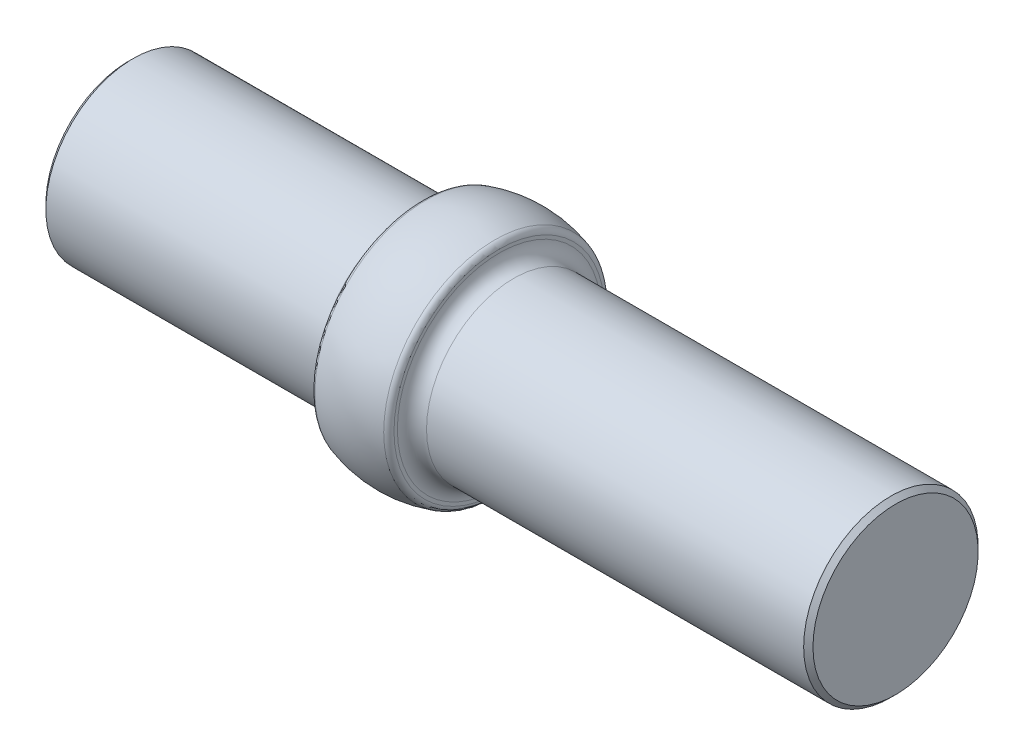
from build123d import *

# Parameters (mm, degrees)
FILLET1_R          = 2.3876
CHAMFER1_SIZE      = 0.762
FILLET2_R          = 1.016
SKETCH2_W          = 1.017628205
SKETCH2_H          = 0.271367522
SKETCH2_W_2        = 1.89957265
SKETCH2_H_2        = 0.169604701
CUT_EXTRUDE1_DEPTH = 0.0254


with BuildPart() as part:
    # Sketch1 → Revolve1 (revolve)
    with BuildSketch(Plane.XY, mode=Mode.PRIVATE) as revolve1_sk:
        with BuildLine():
            Line((71.247, 14.2875), (71.247, 0))
            Line((71.247, 0), (-54.356, 0))
            Line((-54.356, 0), (-54.356, 14.2875))
            Line((-54.356, 14.2875), (-6.35, 14.2875))
            Line((-6.35, 14.2875), (-6.35, 17.960512242))
            ThreePointArc((-6.35, 17.960512242), (0, 19.05), (6.35, 17.960512242))
            Line((6.35, 17.960512242), (6.35, 14.2875))
            Line((6.35, 14.2875), (71.247, 14.2875))
        make_face()
    revolve(revolve1_sk.sketch.rotate(Axis((0, 0, 0), (1, 0, 0)), 90), axis=Axis((0, 0, 0), (1, 0, 0)))  # turned: the seam where the file's is

    # Fillet1
    fillet1_edges = [part.edges().sort_by_distance(p)[0] for p in [
        (6.35, 0, -14.2875),
        (-6.35, 0, -14.2875),
    ]]
    fillet(fillet1_edges, radius=FILLET1_R)

    # Chamfer1
    chamfer1_edges = [part.edges().sort_by_distance(p)[0] for p in [
        (-54.356, 0, -14.2875),
        (71.247, 0, -14.2875),
    ]]
    chamfer(chamfer1_edges, length=CHAMFER1_SIZE)

    # Fillet2
    fillet2_edges = [part.edges().sort_by_distance(p)[0] for p in [
        (6.35, 0, -17.960512242),
        (-6.35, 0, -17.960512242),
    ]]
    fillet(fillet2_edges, radius=FILLET2_R)

    # Sketch2 → Cut-Extrude1 (cut)
    with BuildSketch(Plane.ZY.offset(54.356)):
        with BuildLine():
            Line((-9.921875, 1.016), (-9.921875, 3.661833333))
            Line((-9.921875, 3.661833333), (-9.387620192, 3.661833333))
            add(Edge.make_bspline(
                [(-9.387620192, 3.661833333), (-9.341152564, 3.661498771), (-9.251377349, 3.6608524), (-9.121646511, 3.656754086), (-9.001613547, 3.649504151), (-8.891673231, 3.638943854), (-8.791523744, 3.625976978), (-8.70144551, 3.609723696), (-8.620972759, 3.590531448), (-8.57148098, 3.574168518), (-8.548076923, 3.566430689)],
                knots=[0, 0, 0, 0, 1.314313732, 2.53924729, 3.670748893, 4.714932338, 5.66265055, 6.526160246, 7.303039223, 8, 8, 8, 8], degree=3))
            add(Edge.make_bspline(
                [(-8.548076923, 3.566430689), (-8.517464828, 3.55476581), (-8.45693482, 3.531700574), (-8.370750864, 3.488190751), (-8.289618001, 3.438892751), (-8.213101147, 3.383741593), (-8.142948141, 3.321175687), (-8.076418362, 3.253852771), (-8.016233422, 3.17932468), (-7.961118222, 3.099137041), (-7.911425194, 3.014234477), (-7.868230712, 2.92477877), (-7.832357752, 2.831224214), (-7.802578349, 2.733830977), (-7.779108705, 2.632384906), (-7.763096174, 2.526767876), (-7.752534771, 2.417397299), (-7.751473375, 2.343182079), (-7.750934829, 2.305525741)],
                knots=[0, 0, 0, 0, 0.984719456, 1.947108742, 2.898477687, 3.838006223, 4.779231079, 5.722358779, 6.681677486, 7.655904652, 8.64651281, 9.637519902, 10.640069247, 11.656948941, 12.698408672, 13.768548281, 14.867775369, 16, 16, 16, 16], degree=3))
            add(Edge.make_bspline(
                [(-7.750934829, 2.305525741), (-7.751410299, 2.272822305), (-7.752347261, 2.208376768), (-7.760760494, 2.113398234), (-7.772989021, 2.021237379), (-7.791921242, 1.93233307), (-7.814904095, 1.845906382), (-7.844359138, 1.762878435), (-7.878101447, 1.682487579), (-7.917448677, 1.605820797), (-7.960644843, 1.533186343), (-8.007001161, 1.464715557), (-8.056468186, 1.401385478), (-8.109517623, 1.343004325), (-8.165463933, 1.289660108), (-8.224673397, 1.240907216), (-8.287298798, 1.197699582), (-8.353059642, 1.158339328), (-8.423874335, 1.124003702), (-8.501084186, 1.094952444), (-8.58501847, 1.07087792), (-8.675471163, 1.050791588), (-8.772598554, 1.03485815), (-8.876495868, 1.02417927), (-8.987003474, 1.016957708), (-9.062885418, 1.016325435), (-9.101942274, 1.016)],
                knots=[0, 0, 0, 0, 1.105936401, 2.179363191, 3.223086493, 4.248585256, 5.251745608, 6.245858792, 7.225916811, 8.198733463, 9.158002045, 10.082870192, 10.993790845, 11.873723703, 12.748670949, 13.606408763, 14.465103618, 15.319838547, 16.196477973, 17.123216899, 18.106603292, 19.147568657, 20.255746949, 21.433717677, 22.679120308, 24, 24, 24, 24], degree=3))
            Line((-9.101942274, 1.016), (-9.921875, 1.016))
        make_face()
        with BuildLine():
            Line((-9.684428419, 1.287367521), (-9.380730001, 1.287367521))
            add(Edge.make_bspline(
                [(-9.380730001, 1.287367521), (-9.337090102, 1.28755507), (-9.253154594, 1.287915796), (-9.132460751, 1.291081122), (-9.022182873, 1.296253301), (-8.922305304, 1.303491604), (-8.832884434, 1.313068474), (-8.753733385, 1.323746228), (-8.685111613, 1.337049062), (-8.643587574, 1.349107228), (-8.624399038, 1.354679387)],
                knots=[0, 0, 0, 0, 1.375205317, 2.645023457, 3.804390687, 4.853969522, 5.800190428, 6.637939096, 7.370582563, 8, 8, 8, 8], degree=3))
            add(Edge.make_bspline(
                [(-8.624399038, 1.354679387), (-8.600247598, 1.363185029), (-8.552521574, 1.379993157), (-8.483819801, 1.410652817), (-8.419747542, 1.446970334), (-8.359188177, 1.48733991), (-8.303000765, 1.5331854), (-8.250519439, 1.583509897), (-8.201849863, 1.638569519), (-8.15749488, 1.698295927), (-8.117801103, 1.76231738), (-8.083427019, 1.830004474), (-8.053301159, 1.900615575), (-8.029656032, 1.975234998), (-8.011123418, 2.053195655), (-7.997996541, 2.134503031), (-7.989821124, 2.21914194), (-7.988867529, 2.27670932), (-7.98838141, 2.306055756)],
                knots=[0, 0, 0, 0, 0.998632004, 1.973411704, 2.929992603, 3.868527914, 4.809262121, 5.754881198, 6.702106254, 7.672490631, 8.653608572, 9.636854334, 10.631411391, 11.644891563, 12.686317036, 13.754757253, 14.855430412, 16, 16, 16, 16], degree=3))
            add(Edge.make_bspline(
                [(-7.98838141, 2.306055756), (-7.988769431, 2.336999518), (-7.989531701, 2.397788812), (-7.999112877, 2.486984159), (-8.01311429, 2.572770127), (-8.033361482, 2.655152453), (-8.059162801, 2.734291862), (-8.091362322, 2.809750659), (-8.128151968, 2.882325768), (-8.171924134, 2.950342104), (-8.219863303, 3.014668442), (-8.273065628, 3.073598646), (-8.33068586, 3.127266957), (-8.392095537, 3.176509175), (-8.459025368, 3.219344216), (-8.529898694, 3.257660933), (-8.605755243, 3.290178899), (-8.658530317, 3.307474229), (-8.685350728, 3.316263755)],
                knots=[0, 0, 0, 0, 1.122418816, 2.205001699, 3.251619955, 4.274784885, 5.280384055, 6.268708349, 7.249350384, 8.229342522, 9.199999885, 10.157847722, 11.105861043, 12.055065948, 13.010012805, 13.98527497, 14.976112212, 16, 16, 16, 16], degree=3))
            add(Edge.make_bspline(
                [(-8.685350728, 3.316263755), (-8.707538797, 3.322399388), (-8.754716719, 3.335445427), (-8.831702505, 3.349676513), (-8.9183461, 3.362228723), (-9.015032183, 3.372855932), (-9.121650542, 3.380481466), (-9.238283175, 3.386205019), (-9.364980495, 3.39006539), (-9.452808959, 3.390328996), (-9.498393263, 3.390465812)],
                knots=[0, 0, 0, 0, 0.674548936, 1.434276114, 2.292660221, 3.240891867, 4.284742987, 5.42552168, 6.663806718, 8, 8, 8, 8], degree=3))
            Line((-9.498393263, 3.390465812), (-9.684428419, 3.390465812))
            Line((-9.684428419, 3.390465812), (-9.684428419, 1.287367521))
        make_face(mode=Mode.SUBTRACT)
        with BuildLine():
            add(Edge.make_bspline(
                [(-7.445646368, 2.337856637), (-7.445398401, 2.380263591), (-7.444916724, 2.46263971), (-7.439558215, 2.582673338), (-7.430656617, 2.695280224), (-7.418457532, 2.800465756), (-7.403612154, 2.898257089), (-7.383794494, 2.988392888), (-7.361257435, 3.071290329), (-7.335137431, 3.147219734), (-7.305664519, 3.217204069), (-7.273586239, 3.282537406), (-7.237629519, 3.343120891), (-7.199849353, 3.399921482), (-7.158716418, 3.452009394), (-7.115401261, 3.500120217), (-7.068213295, 3.543142034), (-7.018756616, 3.58233537), (-6.966583455, 3.616693006), (-6.913180964, 3.64695585), (-6.858181568, 3.672809321), (-6.801435109, 3.69313721), (-6.743451627, 3.709927553), (-6.684028428, 3.721409674), (-6.623067397, 3.728634242), (-6.581919824, 3.729324931), (-6.56105185, 3.729675214)],
                knots=[0, 0, 0, 0, 1.646270934, 3.197905019, 4.663502075, 6.030701355, 7.308322542, 8.50163776, 9.611534131, 10.641858119, 11.616356847, 12.558055219, 13.465016945, 14.349605745, 15.204443733, 16.039544428, 16.859896111, 17.680448484, 18.487036065, 19.28249412, 20.06191084, 20.843045899, 21.620316918, 22.403196591, 23.190181807, 24, 24, 24, 24], degree=3))
            add(Edge.make_bspline(
                [(-6.56105185, 3.729675214), (-6.540009553, 3.729306449), (-6.498163047, 3.728573091), (-6.43629562, 3.721524634), (-6.375857468, 3.709829202), (-6.317106256, 3.693257989), (-6.259559391, 3.672699353), (-6.203666988, 3.646931115), (-6.149081872, 3.616935781), (-6.096671477, 3.58169035), (-6.045860428, 3.542394225), (-5.997896789, 3.497972445), (-5.952776195, 3.44887355), (-5.909932363, 3.395622855), (-5.87058081, 3.337199012), (-5.833105656, 3.274618167), (-5.79956251, 3.206785906), (-5.76725713, 3.134834005), (-5.739372325, 3.056771596), (-5.714224627, 2.973038711), (-5.693905407, 2.88264632), (-5.676980183, 2.786068682), (-5.663868268, 2.682951121), (-5.654318592, 2.57351468), (-5.649274058, 2.457687361), (-5.648324051, 2.378495415), (-5.647836538, 2.337856637)],
                knots=[0, 0, 0, 0, 0.810914788, 1.612654377, 2.396697861, 3.181598691, 3.963628158, 4.749916497, 5.551656086, 6.361998678, 7.18212741, 8.025565596, 8.878627764, 9.750805457, 10.657531673, 11.591944965, 12.560506719, 13.57287815, 14.630710178, 15.753379473, 16.941251878, 18.199788006, 19.531962791, 20.947069417, 22.433333509, 24, 24, 24, 24], degree=3))
            add(Edge.make_bspline(
                [(-5.647836538, 2.337856637), (-5.648329105, 2.297395112), (-5.649288852, 2.218557479), (-5.654262041, 2.103251325), (-5.664058149, 1.994395661), (-5.676312128, 1.891729419), (-5.693283987, 1.795679909), (-5.714152178, 1.705914761), (-5.737322363, 1.622046326), (-5.765923666, 1.544761676), (-5.797228191, 1.472982696), (-5.831287773, 1.405954554), (-5.867777463, 1.343084797), (-5.90753205, 1.284876655), (-5.949905762, 1.230917789), (-5.995805519, 1.182160657), (-6.043937449, 1.137430447), (-6.094898025, 1.097628324), (-6.148125805, 1.062790406), (-6.202523441, 1.031634698), (-6.259056117, 1.006512363), (-6.316442695, 0.984941231), (-6.375504019, 0.968461127), (-6.436166469, 0.95706601), (-6.498121481, 0.949074196), (-6.540002426, 0.948464536), (-6.56105185, 0.94815812)],
                knots=[0, 0, 0, 0, 1.561518951, 3.042555995, 4.452378317, 5.7783523, 7.031515105, 8.214008947, 9.334062868, 10.386615937, 11.391082383, 12.354592575, 13.286541444, 14.194233754, 15.072674879, 15.931287219, 16.775624067, 17.606195743, 18.42308326, 19.229000347, 20.022332153, 20.807536673, 21.593273796, 22.3848459, 23.188221202, 24, 24, 24, 24], degree=3))
            add(Edge.make_bspline(
                [(-6.56105185, 0.94815812), (-6.581919245, 0.948510662), (-6.623065677, 0.949205807), (-6.68403507, 0.956397735), (-6.743212869, 0.967960407), (-6.800891094, 0.98415034), (-6.857365662, 1.003967508), (-6.911867021, 1.029786066), (-6.965001163, 1.05952075), (-7.016626328, 1.093383955), (-7.065772426, 1.132180704), (-7.112716014, 1.175091803), (-7.156277784, 1.223188072), (-7.196822607, 1.275710073), (-7.23535659, 1.332174608), (-7.270802723, 1.393352604), (-7.303589024, 1.459001482), (-7.333557615, 1.529545379), (-7.360128331, 1.606013688), (-7.38359892, 1.689281221), (-7.402130455, 1.780082922), (-7.417992571, 1.877689504), (-7.430786598, 1.982520391), (-7.439521118, 2.094632498), (-7.444919612, 2.213955959), (-7.445399695, 2.295802753), (-7.445646368, 2.337856637)],
                knots=[0, 0, 0, 0, 0.810891512, 1.598919785, 2.382837074, 3.152667961, 3.926044502, 4.706494248, 5.493654104, 6.291793342, 7.103789334, 7.925228297, 8.761435821, 9.622817696, 10.50288917, 11.416980706, 12.369136599, 13.353924996, 14.394355917, 15.514179734, 16.714354668, 17.994756427, 19.357759367, 20.818452758, 22.365282078, 24, 24, 24, 24], degree=3))
        make_face()
        with BuildLine():
            add(Edge.make_bspline(
                [(-7.208199786, 2.338916667), (-7.20810949, 2.303576876), (-7.207934243, 2.234989283), (-7.203356043, 2.135322056), (-7.197119261, 2.042362343), (-7.189074947, 1.95599211), (-7.17712867, 1.876503708), (-7.163743182, 1.803350436), (-7.147453852, 1.736919429), (-7.128180833, 1.676754834), (-7.106228658, 1.621835598), (-7.082260535, 1.570732298), (-7.056512251, 1.522841251), (-7.027695988, 1.47859263), (-6.996312577, 1.437842137), (-6.963070887, 1.399868508), (-6.926730303, 1.366004123), (-6.87645664, 1.325389179), (-6.810086686, 1.283419358), (-6.72646289, 1.246872016), (-6.640534954, 1.223904326), (-6.582212282, 1.220983511), (-6.553101629, 1.219525641)],
                knots=[0, 0, 0, 0, 1.459021318, 2.831673884, 4.118529203, 5.306027144, 6.411944654, 7.436330062, 8.375795394, 9.233974572, 10.042671642, 10.816086306, 11.563610507, 12.285937304, 12.993564865, 13.685989202, 14.367179055, 15.041617293, 16.353048772, 17.594441528, 18.799311195, 20, 20, 20, 20], degree=3))
            add(Edge.make_bspline(
                [(-6.553101629, 1.219525641), (-6.523802675, 1.220733487), (-6.465265258, 1.223146686), (-6.379741496, 1.246429065), (-6.296715042, 1.281557824), (-6.231648754, 1.323095521), (-6.182147069, 1.362653247), (-6.146680059, 1.396379796), (-6.114127201, 1.434144053), (-6.083252537, 1.474889354), (-6.05493526, 1.519394149), (-6.02918515, 1.567444429), (-6.005687619, 1.619173629), (-5.992300424, 1.655285277), (-5.985455896, 1.673748231)],
                knots=[0, 0, 0, 0, 1.353760809, 2.704726607, 4.075137775, 5.516104923, 6.260822281, 7.007110065, 7.778089737, 8.566572457, 9.372053459, 10.217411131, 11.088608312, 12, 12, 12, 12], degree=3))
            add(Edge.make_bspline(
                [(-5.985455896, 1.673748231), (-5.977479262, 1.697356426), (-5.961283274, 1.745291189), (-5.940410088, 1.819649426), (-5.923971601, 1.897665801), (-5.909182629, 1.978874074), (-5.899088354, 2.063873133), (-5.890963519, 2.152399983), (-5.886177821, 2.24452137), (-5.885584587, 2.307110441), (-5.88528312, 2.338916667)],
                knots=[0, 0, 0, 0, 0.884706709, 1.796334032, 2.740027952, 3.714592787, 4.726048262, 5.777819803, 6.87074269, 8, 8, 8, 8], degree=3))
            add(Edge.make_bspline(
                [(-5.88528312, 2.338916667), (-5.885699037, 2.370717748), (-5.886512659, 2.432927462), (-5.889622638, 2.524033468), (-5.897653554, 2.610565644), (-5.906573126, 2.692896775), (-5.919724597, 2.770571111), (-5.933904606, 2.844238902), (-5.952955522, 2.912987498), (-5.97330559, 2.977893253), (-5.996596782, 3.038218748), (-6.022235462, 3.094245241), (-6.049617387, 3.146243217), (-6.079358247, 3.194070012), (-6.111104984, 3.237939851), (-6.145695512, 3.276973146), (-6.181757746, 3.312379664), (-6.232268357, 3.35279482), (-6.298394754, 3.394003066), (-6.380676881, 3.431925992), (-6.466304094, 3.453703689), (-6.524189979, 3.456774131), (-6.553101629, 3.458307692)],
                knots=[0, 0, 0, 0, 1.31362396, 2.569729283, 3.763502607, 4.902122613, 5.988968491, 7.01645872, 7.998833611, 8.933434873, 9.825090667, 10.667526885, 11.477055099, 12.250526234, 12.991942729, 13.710640831, 14.402115721, 15.076753259, 16.378508321, 17.609869233, 18.806226677, 20, 20, 20, 20], degree=3))
            add(Edge.make_bspline(
                [(-6.553101629, 3.458307692), (-6.582364994, 3.456772015), (-6.640945033, 3.453697864), (-6.727462237, 3.432007131), (-6.810393503, 3.39419971), (-6.876345037, 3.352658333), (-6.926890876, 3.313093062), (-6.96248315, 3.278783064), (-6.995855554, 3.24125286), (-7.026598399, 3.200127603), (-7.055392083, 3.155930569), (-7.081836063, 3.108314062), (-7.105661663, 3.057036781), (-7.127648187, 3.002142214), (-7.146979997, 2.941982809), (-7.162926029, 2.87563363), (-7.177657313, 2.802713033), (-7.18808588, 2.722794119), (-7.197356695, 2.636402253), (-7.203314619, 2.543210471), (-7.207949557, 2.443376088), (-7.208114706, 2.374433867), (-7.208199786, 2.338916667)],
                knots=[0, 0, 0, 0, 1.207732386, 2.417664972, 3.655092373, 4.956220595, 5.625982001, 6.301752483, 6.994047911, 7.697131622, 8.419323945, 9.170223765, 9.943494443, 10.752040957, 11.610060368, 12.549350801, 13.567764191, 14.679664412, 15.874934091, 17.154273443, 18.533957287, 20, 20, 20, 20], degree=3))
        make_face(mode=Mode.SUBTRACT)
        Polygon((-3.966099927, 3.729675214), (-3.91786859, 3.729675214), (-3.91786859, 1.897944444), (-3.612580128, 1.897944444), (-3.612580128, 1.626576923), (-3.91786859, 1.626576923), (-3.91786859, 1.016), (-4.155315171, 1.016), (-4.155315171, 1.626576923), (-5.410389957, 1.626576923), align=None)
        Polygon((-4.155315171, 1.897944444), (-4.155315171, 3.047016293), (-4.94397703, 1.897944444), align=None, mode=Mode.SUBTRACT)
        Polygon((-3.205528846, 3.661833333), (-1.577323718, 3.661833333), (-2.968082265, 0.94815812), (-3.17319795, 1.061051249), (-1.979074853, 3.390465812), (-3.205528846, 3.390465812), align=None)
        with BuildLine():
            Line((-0.763221154, 0.94815812), (-0.952966413, 1.080131778))
            Line((-0.952966413, 1.080131778), (-0.217306023, 2.155531584))
            add(Edge.make_bspline(
                [(-0.217306023, 2.155531584), (-0.264243662, 2.14979159), (-0.356666491, 2.138489221), (-0.449752277, 2.136412881), (-0.495563735, 2.135391026)],
                knots=[0, 0, 0, 0, 1.015715272, 2, 2, 2, 2], degree=3))
            add(Edge.make_bspline(
                [(-0.495563735, 2.135391026), (-0.523338974, 2.136102435), (-0.577859338, 2.137498868), (-0.658014218, 2.148567378), (-0.73503485, 2.165614201), (-0.808717042, 2.191051057), (-0.879337739, 2.222663632), (-0.946742773, 2.261865065), (-1.010841404, 2.307982916), (-1.07094522, 2.360773333), (-1.125609451, 2.418738289), (-1.174310396, 2.48008809), (-1.214784943, 2.545535402), (-1.248407123, 2.613745151), (-1.27390574, 2.68569772), (-1.292473849, 2.76057435), (-1.303905629, 2.838899817), (-1.305265659, 2.892213458), (-1.305956197, 2.919282752)],
                knots=[0, 0, 0, 0, 1.060718605, 2.082097864, 3.085795603, 4.069760067, 5.054557537, 6.03741023, 7.043284206, 8.066802108, 9.088538119, 10.083643548, 11.053783639, 12.022749082, 12.983451788, 13.964007469, 14.966251758, 16, 16, 16, 16], degree=3))
            add(Edge.make_bspline(
                [(-1.305956197, 2.919282752), (-1.304645046, 2.956300722), (-1.302071525, 3.028959487), (-1.28135955, 3.135120729), (-1.24729608, 3.235501033), (-1.199800819, 3.329836477), (-1.139978738, 3.416770048), (-1.068081172, 3.495093222), (-0.984545438, 3.563692011), (-0.891274506, 3.622659379), (-0.790465973, 3.670084049), (-0.684883118, 3.705038759), (-0.575334944, 3.725599717), (-0.50112486, 3.728310457), (-0.463762854, 3.729675214)],
                knots=[0, 0, 0, 0, 1.022988612, 2.007919123, 2.978103895, 3.94594894, 4.918897164, 5.887013414, 6.875921846, 7.89917871, 8.930658928, 9.948724884, 10.967259574, 12, 12, 12, 12], degree=3))
            add(Edge.make_bspline(
                [(-0.463762854, 3.729675214), (-0.427107918, 3.728291698), (-0.354681219, 3.725558), (-0.248175839, 3.705537381), (-0.146166856, 3.671794182), (-0.049219753, 3.625163589), (0.040541589, 3.566712664), (0.121259018, 3.497063352), (0.191090526, 3.416172269), (0.249921674, 3.325995851), (0.29714605, 3.229107716), (0.33121855, 3.127973441), (0.352192931, 3.02332036), (0.354835988, 2.952416204), (0.356169872, 2.916632679)],
                knots=[0, 0, 0, 0, 1.026385292, 2.028040595, 3.023318987, 4.028184125, 5.03290303, 6.015178782, 7.004435299, 8.016004309, 9.023023918, 10.015172535, 10.998308025, 12, 12, 12, 12], degree=3))
            add(Edge.make_bspline(
                [(0.356169872, 2.916632679), (0.355279051, 2.888856141), (0.353472243, 2.832518381), (0.340820392, 2.746921634), (0.319336085, 2.659646002), (0.294955337, 2.585773129), (0.271420901, 2.524761384), (0.24927064, 2.476568225), (0.224693, 2.425842866), (0.196028219, 2.373117199), (0.165213864, 2.317719093), (0.130395244, 2.260204182), (0.092366628, 2.200495289), (0.065281066, 2.160243026), (0.051411425, 2.139631143)],
                knots=[0, 0, 0, 0, 1.179839688, 2.393009684, 3.667231171, 4.993948276, 5.694988576, 6.444077775, 7.246288328, 8.089075292, 8.993003841, 9.939041771, 10.944649915, 12, 12, 12, 12], degree=3))
            Line((0.051411425, 2.139631143), (-0.763221154, 0.94815812))
        make_face()
        with BuildLine():
            add(Edge.make_bspline(
                [(-0.451572516, 2.406758547), (-0.430531327, 2.407333361), (-0.389571284, 2.408452328), (-0.329565826, 2.415262886), (-0.272926696, 2.427338459), (-0.219502597, 2.44466467), (-0.168757856, 2.465571795), (-0.121498489, 2.492190379), (-0.077684944, 2.523952954), (-0.037023832, 2.559641478), (-0.000916523, 2.599291622), (0.031243983, 2.64079122), (0.05857965, 2.684322443), (0.080172127, 2.730430445), (0.097925348, 2.777992859), (0.110185392, 2.827775615), (0.116977121, 2.879519347), (0.118134918, 2.914670118), (0.118723291, 2.93253312)],
                knots=[0, 0, 0, 0, 1.163407946, 2.26475976, 3.333800367, 4.359385343, 5.366239384, 6.363380779, 7.350133999, 8.353570782, 9.349036268, 10.310270964, 11.253520213, 12.184142, 13.120487599, 14.056272588, 15.012232024, 16, 16, 16, 16], degree=3))
            add(Edge.make_bspline(
                [(0.118723291, 2.93253312), (0.118217053, 2.950403581), (0.117219449, 2.985619517), (0.109215954, 3.037439856), (0.095136172, 3.087100833), (0.076244556, 3.134874324), (0.051358424, 3.18036782), (0.02149567, 3.224152485), (-0.013983028, 3.2659507), (-0.054806396, 3.304779426), (-0.098828945, 3.340572183), (-0.145743728, 3.372160467), (-0.195164051, 3.398634824), (-0.24678841, 3.420481069), (-0.300724364, 3.437529137), (-0.356939998, 3.449788693), (-0.415719382, 3.456570912), (-0.455619521, 3.457721392), (-0.475953192, 3.458307692)],
                knots=[0, 0, 0, 0, 0.972161553, 1.915763587, 2.844109794, 3.775983486, 4.705125789, 5.659731448, 6.655561913, 7.682237399, 8.721216875, 9.739758359, 10.754845918, 11.767244016, 12.7857855, 13.828538656, 14.893392813, 16, 16, 16, 16], degree=3))
            add(Edge.make_bspline(
                [(-0.475953192, 3.458307692), (-0.496110022, 3.457720445), (-0.535657557, 3.456568269), (-0.593914392, 3.449801584), (-0.649749917, 3.437446689), (-0.703529595, 3.420488965), (-0.755152419, 3.398633194), (-0.804570412, 3.37215908), (-0.851496168, 3.340579455), (-0.895476511, 3.304751263), (-0.936371964, 3.266131436), (-0.971240667, 3.223969379), (-1.001171764, 3.180390596), (-1.026023701, 3.134868271), (-1.044924413, 3.087102448), (-1.05900176, 3.037439418), (-1.067005909, 2.985619631), (-1.068003423, 2.950403619), (-1.068509615, 2.93253312)],
                knots=[0, 0, 0, 0, 1.099389452, 2.15699305, 3.192601482, 4.213358962, 5.227959689, 6.245255729, 7.266013209, 8.307253147, 9.336162325, 10.327954924, 11.284637477, 12.215801273, 13.149702402, 14.080068371, 15.025723358, 16, 16, 16, 16], degree=3))
            add(Edge.make_bspline(
                [(-1.068509615, 2.93253312), (-1.068051564, 2.914656208), (-1.067148203, 2.879399665), (-1.058433743, 2.827596975), (-1.043860281, 2.777939828), (-1.024342052, 2.729945389), (-0.998638469, 2.684080353), (-0.967097226, 2.640562169), (-0.930126962, 2.598897513), (-0.888221886, 2.559733728), (-0.842359645, 2.523786548), (-0.79337639, 2.492391557), (-0.742115383, 2.465878459), (-0.688396174, 2.444604913), (-0.632616867, 2.427511572), (-0.574276142, 2.415285142), (-0.513566939, 2.408517654), (-0.472435584, 2.407350542), (-0.451572516, 2.406758547)],
                knots=[0, 0, 0, 0, 0.952633368, 1.87876736, 2.791047057, 3.707742249, 4.635551637, 5.587206343, 6.568248508, 7.601284464, 8.641511608, 9.671105535, 10.699146789, 11.713763218, 12.747829548, 13.806491675, 14.887386225, 16, 16, 16, 16], degree=3))
        make_face(mode=Mode.SUBTRACT)
        with BuildLine():
            Line((1.034588675, 3.05125641), (0.797142094, 3.05125641))
            add(Edge.make_bspline(
                [(0.797142094, 3.05125641), (0.803574909, 3.07789049), (0.816150536, 3.129957939), (0.84238025, 3.204349142), (0.870954687, 3.274746089), (0.905266688, 3.339830621), (0.942692949, 3.400910744), (0.985572625, 3.456601094), (1.031927416, 3.508318038), (1.083199848, 3.554214355), (1.136969729, 3.5957749), (1.193994709, 3.631210211), (1.253127492, 3.661693351), (1.314777777, 3.686806264), (1.379129109, 3.705724368), (1.445599717, 3.719450049), (1.514363792, 3.72836357), (1.56104203, 3.729233492), (1.584743924, 3.729675214)],
                knots=[0, 0, 0, 0, 1.162005537, 2.271625781, 3.343758855, 4.383309926, 5.390229558, 6.379919256, 7.361854164, 8.333198761, 9.295911338, 10.242430842, 11.177959212, 12.116337295, 13.062827104, 14.020064771, 14.994644689, 16, 16, 16, 16], degree=3))
            add(Edge.make_bspline(
                [(1.584743924, 3.729675214), (1.619277901, 3.728632581), (1.68759257, 3.726570059), (1.787955112, 3.707735932), (1.88473729, 3.677932409), (1.976879758, 3.636752865), (2.062467501, 3.585962456), (2.138619261, 3.525512923), (2.204302838, 3.456570594), (2.259407516, 3.380421572), (2.302553498, 3.299039133), (2.334368792, 3.215279491), (2.353737563, 3.129341334), (2.356247746, 3.071316486), (2.357505342, 3.042246161)],
                knots=[0, 0, 0, 0, 1.083050992, 2.142477498, 3.193116406, 4.255571735, 5.30263384, 6.308962982, 7.297363603, 8.282367274, 9.249857812, 10.179914175, 11.08814088, 12, 12, 12, 12], degree=3))
            add(Edge.make_bspline(
                [(2.357505342, 3.042246161), (2.356625722, 3.014270786), (2.354904444, 2.959527319), (2.340289083, 2.879606902), (2.315693218, 2.804282597), (2.281622623, 2.733237313), (2.237519189, 2.666921512), (2.184093996, 2.605185987), (2.12096996, 2.547756921), (2.073134096, 2.514858272), (2.048506778, 2.497921074)],
                knots=[0, 0, 0, 0, 1.024540389, 2.004866551, 2.965041327, 3.920577974, 4.882998113, 5.874504559, 6.905732034, 8, 8, 8, 8], degree=3))
            add(Edge.make_bspline(
                [(2.048506778, 2.497921074), (2.076652211, 2.484330432), (2.132416455, 2.45740344), (2.208427867, 2.404595814), (2.277429595, 2.343623456), (2.315910382, 2.296041808), (2.335244725, 2.272134816)],
                knots=[0, 0, 0, 0, 1.015518401, 2.012035669, 3.001164323, 4, 4, 4, 4], degree=3))
            add(Edge.make_bspline(
                [(2.335244725, 2.272134816), (2.347975978, 2.254704253), (2.37323, 2.220128567), (2.4044021, 2.16453853), (2.432681609, 2.108332345), (2.454717787, 2.050003508), (2.471782555, 1.990228075), (2.483980627, 1.928903407), (2.491558401, 1.865979426), (2.49264361, 1.823409872), (2.493189103, 1.802011786)],
                knots=[0, 0, 0, 0, 1.025084078, 2.033381695, 3.024893161, 4.013698104, 4.991890475, 5.976764909, 6.982997093, 8, 8, 8, 8], degree=3))
            add(Edge.make_bspline(
                [(2.493189103, 1.802011786), (2.491832536, 1.76496277), (2.489125786, 1.691039093), (2.46493223, 1.581823083), (2.427426983, 1.475063328), (2.374164894, 1.372953182), (2.309253146, 1.277415632), (2.232027074, 1.191935327), (2.143364134, 1.11845781), (2.044481293, 1.057066745), (1.937349892, 1.007991887), (1.822765962, 0.973930606), (1.702380505, 0.951746428), (1.619824988, 0.949367545), (1.577853733, 0.94815812)],
                knots=[0, 0, 0, 0, 0.955779014, 1.907060117, 2.875433937, 3.871313158, 4.872415639, 5.851225146, 6.836215519, 7.83643374, 8.849228613, 9.86973379, 10.916971861, 12, 12, 12, 12], degree=3))
            add(Edge.make_bspline(
                [(1.577853733, 0.94815812), (1.549566523, 0.948814448), (1.493906729, 0.950105882), (1.412079798, 0.958934348), (1.333973514, 0.975058817), (1.25948227, 0.996757149), (1.188539891, 1.024267573), (1.121362859, 1.05852635), (1.05753788, 1.098827307), (0.997667245, 1.14564615), (0.941758089, 1.198019544), (0.891296209, 1.256877248), (0.845440294, 1.321131238), (0.80541818, 1.391527834), (0.769406912, 1.467157284), (0.739787975, 1.548987995), (0.713718527, 1.636288416), (0.701597991, 1.697125755), (0.695379274, 1.728339744)],
                knots=[0, 0, 0, 0, 1.048658725, 2.063410685, 3.046034179, 4.001477787, 4.936774919, 5.862367409, 6.792675028, 7.730719943, 8.675894397, 9.627829632, 10.600096036, 11.597688215, 12.626045268, 13.701542398, 14.82072376, 16, 16, 16, 16], degree=3))
            Line((0.695379274, 1.728339744), (0.932825855, 1.728339744))
            add(Edge.make_bspline(
                [(0.932825855, 1.728339744), (0.939012033, 1.707967573), (0.951044688, 1.668341931), (0.971526687, 1.611312653), (0.994861631, 1.559032458), (1.01989466, 1.511117836), (1.04618551, 1.467096912), (1.07560334, 1.428133714), (1.105969301, 1.392516864), (1.12885905, 1.372450402), (1.140061599, 1.362629607)],
                knots=[0, 0, 0, 0, 1.198163088, 2.33053128, 3.407730985, 4.417276592, 5.372219308, 6.28897303, 7.162600585, 8, 8, 8, 8], degree=3))
            add(Edge.make_bspline(
                [(1.140061599, 1.362629607), (1.154875677, 1.351208426), (1.184458107, 1.328401319), (1.232663853, 1.299295921), (1.283361713, 1.274076575), (1.337650187, 1.254812114), (1.394357782, 1.23850043), (1.454401088, 1.22782599), (1.517250377, 1.220502194), (1.560164103, 1.219855906), (1.58209385, 1.219525641)],
                knots=[0, 0, 0, 0, 0.946170439, 1.889420265, 2.845303464, 3.807233317, 4.801018734, 5.828864929, 6.890507805, 8, 8, 8, 8], degree=3))
            add(Edge.make_bspline(
                [(1.58209385, 1.219525641), (1.606853938, 1.219991236), (1.655270154, 1.220901667), (1.725917577, 1.229274374), (1.793127374, 1.241468198), (1.856153336, 1.260301227), (1.91582104, 1.283570085), (1.971294073, 1.312786439), (2.023300654, 1.347064889), (2.071174668, 1.386026039), (2.11422276, 1.428678003), (2.152125845, 1.473289074), (2.184348059, 1.51967116), (2.210340407, 1.56808093), (2.23086493, 1.618317918), (2.244837349, 1.670523105), (2.254552483, 1.724269252), (2.255343672, 1.760803651), (2.255742521, 1.779221154)],
                knots=[0, 0, 0, 0, 1.217147791, 2.380027433, 3.494444702, 4.572153297, 5.609568379, 6.639424714, 7.649109417, 8.668170816, 9.669597737, 10.625200337, 11.543417969, 12.441394052, 13.322311151, 14.205496177, 15.095365482, 16, 16, 16, 16], degree=3))
            add(Edge.make_bspline(
                [(2.255742521, 1.779221154), (2.254585686, 1.803873773), (2.252277772, 1.853056344), (2.234657596, 1.925414272), (2.205675241, 1.99513078), (2.165101378, 2.061016407), (2.115710678, 2.122079142), (2.057982445, 2.176561751), (1.991437296, 2.221518308), (1.930190133, 2.252579375), (1.875939092, 2.273774069), (1.829511986, 2.287891453), (1.777535268, 2.299845824), (1.720637493, 2.3109676), (1.658389942, 2.320433143), (1.590860385, 2.328326659), (1.518035136, 2.334642672), (1.467619791, 2.337463202), (1.441639957, 2.338916667)],
                knots=[0, 0, 0, 0, 1.07054697, 2.135767047, 3.216561865, 4.33974944, 5.486079747, 6.621378074, 7.775625952, 8.963672916, 9.598146892, 10.304877434, 11.070270905, 11.915000392, 12.823868403, 13.805723172, 14.86925407, 16, 16, 16, 16], degree=3))
            Line((1.441639957, 2.338916667), (1.441639957, 2.610284188))
            add(Edge.make_bspline(
                [(1.441639957, 2.610284188), (1.474373577, 2.610839665), (1.538490696, 2.611927707), (1.63214889, 2.625087334), (1.721709073, 2.643291142), (1.805186431, 2.671174591), (1.881272066, 2.703559815), (1.947281527, 2.741245712), (2.002290025, 2.783136623), (2.04603024, 2.829879132), (2.078936264, 2.88001015), (2.102995807, 2.932259052), (2.117207959, 2.987083788), (2.119105147, 3.0244994), (2.120058761, 3.04330619)],
                knots=[0, 0, 0, 0, 1.321986639, 2.589447074, 3.816329219, 5.01088745, 6.139805852, 7.153945165, 8.075214402, 8.924034688, 9.728124013, 10.488707548, 11.240355623, 12, 12, 12, 12], degree=3))
            add(Edge.make_bspline(
                [(2.120058761, 3.04330619), (2.119745486, 3.057123295), (2.11912224, 3.08461177), (2.111262393, 3.124771792), (2.099451362, 3.163704055), (2.08321371, 3.201242995), (2.061479929, 3.237128261), (2.035470641, 3.271665797), (2.004500708, 3.304658416), (1.969012186, 3.3354108), (1.930903262, 3.364718497), (1.889137063, 3.389599639), (1.844972907, 3.410875966), (1.7983619, 3.428421245), (1.749152779, 3.441619635), (1.697576751, 3.451096134), (1.643535466, 3.457021028), (1.606666359, 3.457874057), (1.587924012, 3.458307692)],
                knots=[0, 0, 0, 0, 0.884392785, 1.759457502, 2.611959086, 3.489218968, 4.37281399, 5.2945488, 6.255912374, 7.266815255, 8.301784654, 9.332968512, 10.37626691, 11.440494194, 12.520033166, 13.637162961, 14.798855837, 16, 16, 16, 16], degree=3))
            add(Edge.make_bspline(
                [(1.587924012, 3.458307692), (1.557798048, 3.457255889), (1.498955035, 3.455201472), (1.414125902, 3.437207527), (1.335265453, 3.408497905), (1.274986818, 3.374228301), (1.230474396, 3.340399104), (1.198666234, 3.310854681), (1.167429896, 3.278021534), (1.138820366, 3.239877405), (1.109887063, 3.199005487), (1.083546233, 3.153328061), (1.057949918, 3.104036644), (1.042526562, 3.069190539), (1.034588675, 3.05125641)],
                knots=[0, 0, 0, 0, 1.472543308, 2.876219568, 4.221790263, 5.565193594, 6.249813518, 6.953379497, 7.687249741, 8.463570142, 9.283606569, 10.136032583, 11.040678096, 12, 12, 12, 12], degree=3))
        make_face()
        with BuildLine():
            Line((4.392761752, 3.661833333), (4.392761752, 3.390465812))
            Line((4.392761752, 3.390465812), (3.492796808, 3.390465812))
            Line((3.492796808, 3.390465812), (3.350222857, 2.694556524))
            add(Edge.make_bspline(
                [(3.350222857, 2.694556524), (3.378235333, 2.702290122), (3.432505076, 2.717272746), (3.512605685, 2.73390806), (3.588648601, 2.743936104), (3.637993672, 2.745305369), (3.661871494, 2.745967949)],
                knots=[0, 0, 0, 0, 1.100273476, 2.13160584, 3.095893838, 4, 4, 4, 4], degree=3))
            add(Edge.make_bspline(
                [(3.661871494, 2.745967949), (3.69141694, 2.745328462), (3.749510669, 2.74407107), (3.834509159, 2.731997113), (3.915647715, 2.712992534), (3.99275665, 2.686443092), (4.065978614, 2.652493472), (4.134639925, 2.610084589), (4.199771205, 2.560544511), (4.260203999, 2.50358727), (4.315028922, 2.440902476), (4.363232974, 2.373503372), (4.404177313, 2.30204496), (4.437107169, 2.2258445), (4.46340247, 2.145744426), (4.480904275, 2.060901938), (4.492558573, 1.972116752), (4.493860615, 1.911410321), (4.494524573, 1.88045396)],
                knots=[0, 0, 0, 0, 1.052922333, 2.070308379, 3.05430497, 4.020497103, 4.973039431, 5.925935799, 6.892292201, 7.88610001, 8.88166317, 9.857072816, 10.836096531, 11.812156883, 12.81219415, 13.836441305, 14.89672472, 16, 16, 16, 16], degree=3))
            add(Edge.make_bspline(
                [(4.494524573, 1.88045396), (4.494021807, 1.858892519), (4.493023071, 1.816061023), (4.487944139, 1.752452014), (4.478165354, 1.690189634), (4.465036181, 1.629265624), (4.447995187, 1.569795324), (4.427365961, 1.511608515), (4.402120155, 1.455067354), (4.37442858, 1.399636847), (4.343248206, 1.346570118), (4.308641835, 1.29694261), (4.272079827, 1.25000985), (4.232739017, 1.206275183), (4.190253741, 1.166025996), (4.145138528, 1.129023427), (4.097753377, 1.094641707), (4.047365188, 1.064276464), (3.995096764, 1.036334229), (3.94019329, 1.013411079), (3.883904546, 0.992916811), (3.825420384, 0.976581037), (3.764873276, 0.963780832), (3.702163416, 0.955086925), (3.637619695, 0.948754738), (3.593868942, 0.948358349), (3.571768997, 0.94815812)],
                knots=[0, 0, 0, 0, 1.056347294, 2.098418968, 3.122841568, 4.141288669, 5.149314143, 6.15115421, 7.162517403, 8.180376062, 9.185164535, 10.17417709, 11.141909838, 12.097768115, 13.052685741, 14.0056014, 14.954263652, 15.917497458, 16.885230207, 17.854509472, 18.828990115, 19.81800267, 20.826176721, 21.857883937, 22.917946725, 24, 24, 24, 24], degree=3))
            add(Edge.make_bspline(
                [(3.571768997, 0.94815812), (3.545405777, 0.94868036), (3.493539256, 0.949707807), (3.417550494, 0.960456305), (3.344438858, 0.975850456), (3.274792889, 0.999010017), (3.207988421, 1.028028984), (3.144924819, 1.064704899), (3.083990691, 1.106266484), (3.027663139, 1.155312941), (2.975384411, 1.20892182), (2.928586038, 1.267098132), (2.886907679, 1.328881698), (2.851016763, 1.394572564), (2.820402188, 1.463998121), (2.796351572, 1.537418484), (2.776939958, 1.614450035), (2.768727729, 1.667482748), (2.764556624, 1.694418803)],
                knots=[0, 0, 0, 0, 1.0467383, 2.05933395, 3.04377827, 4.011590433, 4.970194871, 5.932262533, 6.905835911, 7.896367577, 8.894135286, 9.877477877, 10.858688626, 11.851381753, 12.8477658, 13.868841284, 14.917554742, 16, 16, 16, 16], degree=3))
            Line((2.764556624, 1.694418803), (3.002003205, 1.694418803))
            add(Edge.make_bspline(
                [(3.002003205, 1.694418803), (3.007845626, 1.669187795), (3.019075085, 1.620692395), (3.043723478, 1.552557393), (3.073860182, 1.491839885), (3.109695612, 1.437736688), (3.152444742, 1.390558458), (3.201225917, 1.348514607), (3.255917351, 1.310584599), (3.316690804, 1.278968578), (3.380805453, 1.252004699), (3.447909237, 1.234049549), (3.516175023, 1.221424469), (3.562347362, 1.220160698), (3.585549379, 1.219525641)],
                knots=[0, 0, 0, 0, 1.136247022, 2.183929868, 3.172523383, 4.106158343, 5.02341133, 5.958108904, 6.928429099, 7.938127109, 8.96079061, 9.975095812, 10.982467395, 12, 12, 12, 12], degree=3))
            add(Edge.make_bspline(
                [(3.585549379, 1.219525641), (3.608196536, 1.22014611), (3.652788975, 1.221367819), (3.718414249, 1.230771119), (3.781772791, 1.245253331), (3.842239424, 1.266926376), (3.900872254, 1.293267324), (3.95618814, 1.327069792), (4.009787339, 1.365971116), (4.060003845, 1.41053952), (4.105995571, 1.459653516), (4.146632639, 1.512175117), (4.180481853, 1.568203923), (4.209007043, 1.626769938), (4.230667572, 1.688515037), (4.246119981, 1.753149854), (4.255193721, 1.820834036), (4.256441935, 1.866999526), (4.257077991, 1.890524239)],
                knots=[0, 0, 0, 0, 1.027316725, 2.022795036, 3.002884548, 3.971462791, 4.93288096, 5.914575861, 6.907176829, 7.935150275, 8.956128384, 9.956726525, 10.942570165, 11.921478529, 12.907843606, 13.90538589, 14.932640048, 16, 16, 16, 16], degree=3))
            add(Edge.make_bspline(
                [(4.257077991, 1.890524239), (4.256580212, 1.91174817), (4.255605881, 1.953290996), (4.247645271, 2.014068967), (4.233798512, 2.071576565), (4.214579269, 2.126091492), (4.190177499, 2.177665165), (4.160357965, 2.226350812), (4.124561051, 2.271506745), (4.083670159, 2.313154092), (4.038873902, 2.351590397), (3.989401549, 2.384356462), (3.93628839, 2.411921447), (3.880174347, 2.435709756), (3.819724692, 2.452794843), (3.756136523, 2.465621756), (3.688723179, 2.473041703), (3.642632242, 2.474071226), (3.618940304, 2.474600427)],
                knots=[0, 0, 0, 0, 1.045622112, 2.046656509, 3.013763289, 3.955457236, 4.890082067, 5.820317437, 6.762574623, 7.722996705, 8.69280354, 9.665887285, 10.63943826, 11.638615906, 12.663482002, 13.728887084, 14.832589034, 16, 16, 16, 16], degree=3))
            add(Edge.make_bspline(
                [(3.618940304, 2.474600427), (3.598432126, 2.474161528), (3.556087941, 2.473255312), (3.491134375, 2.466582901), (3.422878132, 2.455818673), (3.351580865, 2.441012402), (3.277028457, 2.421636529), (3.199378237, 2.398417829), (3.118466941, 2.370657746), (3.063949375, 2.349693513), (3.035924145, 2.338916667)],
                knots=[0, 0, 0, 0, 0.817624296, 1.688186739, 2.600797293, 3.572016777, 4.590301741, 5.671205678, 6.80286297, 8, 8, 8, 8], degree=3))
            Line((3.035924145, 2.338916667), (3.307291667, 3.661833333))
            Line((3.307291667, 3.661833333), (4.392761752, 3.661833333))
        make_face()
        with Locations((5.274706197, 2.033628205)):
            Rectangle(SKETCH2_W, SKETCH2_H)
        Polygon((6.02096688, 3.661833333), (6.275373932, 3.661833333), (7.157318376, 1.576755542), (8.039262821, 3.661833333), (8.293669872, 3.661833333), (7.174278846, 1.016), (7.140357906, 1.016), align=None)
        with Locations((9.345219017, 0.659830129)):
            Rectangle(SKETCH2_W_2, SKETCH2_H_2)
        with BuildLine():
            add(Edge.make_bspline(
                [(-1.95045406, 8.479475214), (-1.901462218, 8.478234333), (-1.805238198, 8.475797142), (-1.663818484, 8.457140915), (-1.528809096, 8.424865233), (-1.399110241, 8.381879526), (-1.276273289, 8.324537223), (-1.15937365, 8.255227617), (-1.048689466, 8.17322458), (-0.945712588, 8.079162009), (-0.851477869, 7.976818565), (-0.768454729, 7.867600145), (-0.698875138, 7.752167122), (-0.641735882, 7.630866375), (-0.596908957, 7.503972232), (-0.565976109, 7.370808195), (-0.546216912, 7.232237066), (-0.54390689, 7.13772271), (-0.542735043, 7.089776696)],
                knots=[0, 0, 0, 0, 1.065120563, 2.091984664, 3.0946048, 4.079830382, 5.057816894, 6.036188127, 7.030412546, 8.04752943, 9.064399622, 10.05169764, 11.02544977, 11.989514704, 12.962713494, 13.945757189, 14.957906945, 16, 16, 16, 16], degree=3))
            add(Edge.make_bspline(
                [(-0.542735043, 7.089776696), (-0.543906718, 7.042183865), (-0.546216225, 6.94837288), (-0.565998575, 6.81068111), (-0.597023617, 6.678320881), (-0.641319604, 6.551513155), (-0.698186483, 6.430124164), (-0.76822938, 6.314473312), (-0.850734939, 6.204522685), (-0.944629403, 6.101476801), (-1.046986143, 6.006984665), (-1.156773309, 5.924647182), (-1.271521831, 5.853796207), (-1.392708337, 5.79726331), (-1.518725626, 5.752078585), (-1.650701549, 5.721271537), (-1.788017694, 5.701399784), (-1.881658274, 5.69911793), (-1.929253472, 5.69795812)],
                knots=[0, 0, 0, 0, 1.043624062, 2.057103931, 3.04512605, 4.022047818, 4.998200453, 5.980619268, 6.982898556, 8.009068085, 9.034988726, 10.034168286, 11.015286542, 11.987931943, 12.962482838, 13.94673481, 14.956375938, 16, 16, 16, 16], degree=3))
            add(Edge.make_bspline(
                [(-1.929253472, 5.69795812), (-1.977199237, 5.699129382), (-2.071713103, 5.701438253), (-2.210458362, 5.721230148), (-2.343715942, 5.752179824), (-2.471104767, 5.796410172), (-2.592695874, 5.853573197), (-2.708727068, 5.923275317), (-2.818732614, 6.005981906), (-2.921800482, 6.099845924), (-3.016104935, 6.202029181), (-3.098321844, 6.31151698), (-3.168039638, 6.426161284), (-3.225010729, 6.546280246), (-3.270114219, 6.671293182), (-3.300885123, 6.802033995), (-3.320793849, 6.937757312), (-3.323088048, 7.030167122), (-3.324252137, 7.077056343)],
                knots=[0, 0, 0, 0, 1.053102029, 2.075944431, 3.073151272, 4.055350789, 5.033113405, 6.020478099, 7.024410459, 8.052272461, 9.079885166, 10.07527673, 11.055994387, 12.023226415, 12.992069828, 13.970394897, 14.97016774, 16, 16, 16, 16], degree=3))
            add(Edge.make_bspline(
                [(-3.324252137, 7.077056343), (-3.323847978, 7.108528659), (-3.323044758, 7.171076252), (-3.313374848, 7.263957551), (-3.299343086, 7.355345132), (-3.279233307, 7.444979122), (-3.252932463, 7.532640105), (-3.221899085, 7.618932646), (-3.18399575, 7.702982246), (-3.141147879, 7.785187072), (-3.093324965, 7.864265668), (-3.040502225, 7.939013924), (-2.984535012, 8.010059082), (-2.923179352, 8.075560091), (-2.858457396, 8.137422438), (-2.789319217, 8.194695445), (-2.716186687, 8.247895557), (-2.638745127, 8.295838314), (-2.55890274, 8.339199089), (-2.476597081, 8.376408464), (-2.392945982, 8.408344475), (-2.307557647, 8.434228908), (-2.220658825, 8.45466384), (-2.132059857, 8.468578923), (-2.041831327, 8.478273497), (-1.981044199, 8.479072918), (-1.95045406, 8.479475214)],
                knots=[0, 0, 0, 0, 1.037015668, 2.060948919, 3.074880161, 4.083647147, 5.086022904, 6.090072063, 7.104153813, 8.122640571, 9.144368836, 10.147691507, 11.138137339, 12.123020368, 13.103399296, 14.087645067, 15.080126199, 16.082011238, 17.087798457, 18.072939717, 19.057185487, 20.037253025, 21.01195951, 21.997135196, 22.992090687, 24, 24, 24, 24], degree=3))
        make_face()
        with BuildLine():
            add(Edge.make_bspline(
                [(-1.938793737, 8.208107692), (-1.963902418, 8.207801615), (-2.01387974, 8.207192385), (-2.088178169, 8.19916741), (-2.161499452, 8.187729934), (-2.233858732, 8.171415332), (-2.304953248, 8.149187268), (-2.375445688, 8.123605153), (-2.444693235, 8.092443972), (-2.512467282, 8.057237225), (-2.57817094, 8.018268696), (-2.640168637, 7.975200753), (-2.698620874, 7.929043393), (-2.753384534, 7.879688897), (-2.804298813, 7.826885924), (-2.852365819, 7.771434976), (-2.895658896, 7.711751106), (-2.935335492, 7.649452762), (-2.970840943, 7.584621091), (-3.002413562, 7.517938635), (-3.028239926, 7.448861455), (-3.049302556, 7.378138967), (-3.066764913, 7.305883179), (-3.077827463, 7.23154596), (-3.085940615, 7.155500846), (-3.086515022, 7.104109801), (-3.086805556, 7.078116373)],
                knots=[0, 0, 0, 0, 1.008559885, 2.007477868, 2.99961109, 3.989939068, 4.984837346, 5.991145699, 7.001802488, 8.033829008, 9.059044045, 10.069351652, 11.065060232, 12.050310815, 13.029377138, 14.011219647, 14.996725999, 15.989392538, 16.977580475, 17.965360261, 18.951710183, 19.937753436, 20.929683414, 21.935841486, 22.955955122, 24, 24, 24, 24], degree=3))
            add(Edge.make_bspline(
                [(-3.086805556, 7.078116373), (-3.085841821, 7.039893742), (-3.083945856, 6.964698002), (-3.067346978, 6.854504226), (-3.041779176, 6.748604152), (-3.004089381, 6.647577233), (-2.956955286, 6.550555067), (-2.898726625, 6.458398345), (-2.829739102, 6.37108216), (-2.751374412, 6.289216094), (-2.665707842, 6.214493372), (-2.574742028, 6.148904367), (-2.479451504, 6.093409714), (-2.379587773, 6.048199927), (-2.275683979, 6.012375542), (-2.167070592, 5.987823244), (-2.054471137, 5.971664417), (-1.977718797, 5.970112631), (-1.938793737, 5.969325641)],
                knots=[0, 0, 0, 0, 1.032063989, 2.030389145, 3.003944642, 3.970395727, 4.937377036, 5.913328081, 6.909231446, 7.93887556, 8.970685674, 9.976071282, 10.964166581, 11.944589148, 12.933237628, 13.927779006, 14.949070134, 16, 16, 16, 16], degree=3))
            add(Edge.make_bspline(
                [(-1.938793737, 5.969325641), (-1.912630601, 5.9696851), (-1.860741247, 5.970398014), (-1.783561893, 5.977578562), (-1.707772971, 5.989093129), (-1.633480784, 6.005671661), (-1.560769647, 6.026420442), (-1.489336075, 6.051070331), (-1.419940939, 6.081823384), (-1.3517088, 6.115801895), (-1.286397355, 6.154537014), (-1.22404978, 6.196143235), (-1.166237581, 6.242232609), (-1.11151489, 6.290853812), (-1.060391578, 6.342987197), (-1.013213357, 6.398564984), (-0.970139091, 6.457937981), (-0.93047756, 6.520141829), (-0.895096522, 6.585150901), (-0.864269465, 6.652075122), (-0.838116449, 6.720749699), (-0.81700383, 6.791273684), (-0.800459463, 6.863513135), (-0.789059761, 6.937564778), (-0.781085644, 7.013280471), (-0.780484604, 7.0644916), (-0.780181624, 7.090306711)],
                knots=[0, 0, 0, 0, 1.047197238, 2.076906641, 3.100256066, 4.114471768, 5.12198147, 6.126382909, 7.136867548, 8.15857795, 9.17633901, 10.174870724, 11.156907918, 12.133735059, 13.104061851, 14.077631395, 15.04955518, 16.038496417, 17.029181396, 18.010275684, 18.986308667, 19.968651475, 20.955262928, 21.950658345, 22.966943676, 24, 24, 24, 24], degree=3))
            add(Edge.make_bspline(
                [(-0.780181624, 7.090306711), (-0.780484846, 7.115945217), (-0.781086344, 7.166803917), (-0.789055952, 7.241991559), (-0.800471506, 7.315510356), (-0.816923077, 7.387071683), (-0.838127658, 7.456693783), (-0.864274033, 7.524311264), (-0.895105777, 7.590176031), (-0.930490566, 7.654125291), (-0.970265623, 7.715489528), (-1.013728533, 7.774153256), (-1.061629718, 7.829014793), (-1.112600583, 7.88142852), (-1.167914287, 7.930276567), (-1.227320272, 7.975575139), (-1.290097338, 8.018417436), (-1.356566141, 8.057065926), (-1.425164248, 8.092757638), (-1.495553967, 8.12333667), (-1.566937869, 8.149320356), (-1.639134431, 8.171482585), (-1.712751325, 8.187666036), (-1.787291124, 8.199177717), (-1.8626507, 8.207189592), (-1.913332182, 8.207800688), (-1.938793737, 8.208107692)],
                knots=[0, 0, 0, 0, 1.02996197, 2.043119294, 3.035359645, 4.018872909, 4.991431989, 5.957985074, 6.929999688, 7.912076566, 8.892894881, 9.867085534, 10.843653904, 11.817741046, 12.803660682, 13.806313499, 14.818574707, 15.856120519, 16.894564902, 17.924820532, 18.937903209, 19.946497019, 20.957711757, 21.963978472, 22.977135795, 24, 24, 24, 24], degree=3))
        make_face(mode=Mode.SUBTRACT)
        with BuildLine():
            Line((0, 8.411633333), (0.237446581, 8.411633333))
            Line((0.237446581, 8.411633333), (0.237446581, 6.826359395))
            add(Edge.make_bspline(
                [(0.237446581, 6.826359395), (0.237411245, 6.803922172), (0.237344188, 6.761343675), (0.237792101, 6.700740258), (0.239046504, 6.646861672), (0.239837351, 6.599500237), (0.241596704, 6.558873279), (0.243031537, 6.524760693), (0.244876482, 6.497324004), (0.247093779, 6.481312233), (0.248046875, 6.474429641)],
                knots=[0, 0, 0, 0, 1.528628734, 2.90083645, 4.128790002, 5.200304208, 6.127813768, 6.898992206, 7.526736466, 8, 8, 8, 8], degree=3))
            add(Edge.make_bspline(
                [(0.248046875, 6.474429641), (0.251960787, 6.449599052), (0.259568077, 6.401336989), (0.278955517, 6.332614657), (0.306031842, 6.270678376), (0.338116762, 6.213595435), (0.380399152, 6.162954669), (0.431050634, 6.116303598), (0.492417162, 6.075503484), (0.560649882, 6.03819662), (0.634192889, 6.008211707), (0.709343072, 5.985538152), (0.7849708, 5.971720174), (0.835601592, 5.970120171), (0.860743857, 5.969325641)],
                knots=[0, 0, 0, 0, 1.035780045, 2.013197591, 2.933192213, 3.817615948, 4.702609284, 5.640816605, 6.646850145, 7.73207398, 8.84249596, 9.914020372, 10.964143139, 12, 12, 12, 12], degree=3))
            add(Edge.make_bspline(
                [(0.860743857, 5.969325641), (0.882329125, 5.970137421), (0.92537499, 5.971756291), (0.989333423, 5.981781302), (1.051623981, 5.999848991), (1.112554257, 6.02316238), (1.169667204, 6.053965619), (1.222994687, 6.089548932), (1.270592423, 6.131285725), (1.314027933, 6.177474676), (1.351851962, 6.229589882), (1.384638479, 6.28649657), (1.411494391, 6.349051135), (1.42475646, 6.393013109), (1.431569678, 6.41559801)],
                knots=[0, 0, 0, 0, 0.994687771, 1.983630487, 2.973142513, 3.978332533, 4.983357753, 5.956394766, 6.925816176, 7.893390482, 8.871859704, 9.88551698, 10.913711441, 12, 12, 12, 12], degree=3))
            add(Edge.make_bspline(
                [(1.431569678, 6.41559801), (1.43383763, 6.424932944), (1.438891541, 6.44573494), (1.443614009, 6.48090282), (1.448532633, 6.522396565), (1.451945433, 6.570514305), (1.455272546, 6.625094802), (1.457263023, 6.686422389), (1.458183042, 6.754274378), (1.458457211, 6.801625089), (1.458600427, 6.826359395)],
                knots=[0, 0, 0, 0, 0.558680831, 1.244966039, 2.062412453, 2.990489873, 4.051219941, 5.244515665, 6.560634259, 8, 8, 8, 8], degree=3))
            Line((1.458600427, 6.826359395), (1.458600427, 8.411633333))
            Line((1.458600427, 8.411633333), (1.696047009, 8.411633333))
            Line((1.696047009, 8.411633333), (1.696047009, 6.813639042))
            add(Edge.make_bspline(
                [(1.696047009, 6.813639042), (1.695854906, 6.784838482), (1.695480005, 6.728632438), (1.692228974, 6.646270398), (1.687045409, 6.568140466), (1.679721676, 6.494232138), (1.670017512, 6.424809887), (1.659226126, 6.359265211), (1.645483264, 6.298068604), (1.629431824, 6.240742907), (1.611082178, 6.186174096), (1.587314167, 6.134384846), (1.560534932, 6.083800746), (1.528773855, 6.035186878), (1.493084298, 5.988327996), (1.452677372, 5.943508278), (1.408889465, 5.900011499), (1.360992655, 5.858953408), (1.309776484, 5.82130042), (1.255393302, 5.78819139), (1.198260863, 5.760203299), (1.138527678, 5.737164951), (1.076168257, 5.719842605), (1.011181027, 5.7069346), (0.943418065, 5.699600126), (0.897331688, 5.698510095), (0.873994224, 5.69795812)],
                knots=[0, 0, 0, 0, 1.316592851, 2.569410997, 3.76748051, 4.895814652, 5.963796859, 6.97159953, 7.931736103, 8.829262218, 9.692595152, 10.560224239, 11.431080259, 12.30701507, 13.211635791, 14.121146779, 15.063487852, 16.031507147, 17.00238618, 17.966455255, 18.938106653, 19.907068911, 20.888905087, 21.893141452, 22.933117798, 24, 24, 24, 24], degree=3))
            add(Edge.make_bspline(
                [(0.873994224, 5.69795812), (0.848541986, 5.698551365), (0.798604785, 5.69971531), (0.725021842, 5.706384889), (0.654480753, 5.718947603), (0.586236489, 5.734943513), (0.52121816, 5.757005029), (0.458554664, 5.782781588), (0.399319232, 5.814438802), (0.342550891, 5.849661189), (0.2897667, 5.889291719), (0.241312116, 5.932486969), (0.197107142, 5.978554993), (0.157896878, 6.027994555), (0.123031685, 6.080421143), (0.092997536, 6.135983068), (0.067209548, 6.194658819), (0.053899821, 6.235444869), (0.047171307, 6.256063588)],
                knots=[0, 0, 0, 0, 1.13879206, 2.234305948, 3.301075583, 4.341971843, 5.366689343, 6.369221514, 7.369726634, 8.367512178, 9.355451585, 10.318319045, 11.268648973, 12.207971039, 13.137398894, 14.081662264, 15.030215811, 16, 16, 16, 16], degree=3))
            add(Edge.make_bspline(
                [(0.047171307, 6.256063588), (0.043257622, 6.270148927), (0.034768752, 6.300700341), (0.0256782, 6.351263342), (0.018036216, 6.409482952), (0.010850466, 6.475363158), (0.006610361, 6.548955021), (0.002893012, 6.630226642), (-2.6188e-05, 6.719276292), (-8.973e-06, 6.781305598), (0, 6.813639042)],
                knots=[0, 0, 0, 0, 0.625038921, 1.35572334, 2.194682327, 3.136881307, 4.189498639, 5.346923369, 6.617055217, 8, 8, 8, 8], degree=3))
            Line((0, 6.813639042), (0, 8.411633333))
        make_face()
        Polygon((2.06917735, 8.140265812), (2.06917735, 8.411633333), (3.459935897, 8.411633333), (3.459935897, 8.140265812), (2.883279915, 8.140265812), (2.883279915, 5.7658), (2.645833333, 5.7658), (2.645833333, 8.140265812), align=None)
    extrude(amount=-CUT_EXTRUDE1_DEPTH, mode=Mode.SUBTRACT)


solid = part.part
